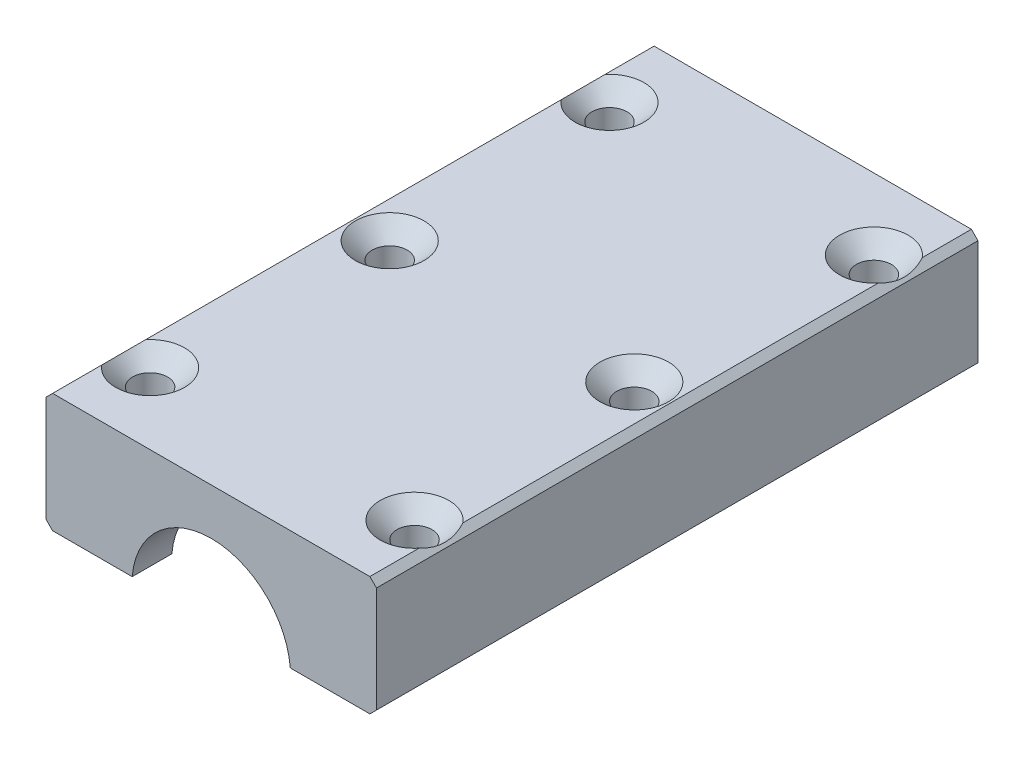
from build123d import *

# Parameters (mm, degrees)
BOSS_EXTRUDE1_DEPTH         = 91
CHAMFER1_SIZE               = 1
SKETCH2_W                   = 6.524852915
SKETCH2_H                   = 18.5
SKETCH2_W_2                 = 5.135295392
SKETCH2_H_2                 = 9.5
HOLE_WIZARD_M51_D           = 5.3
HOLE_WIZARD_M51_CSINK_D     = 10.4
HOLE_WIZARD_M51_CSINK_ANGLE = 90


with BuildPart() as part:
    # Sketch1 → Boss-Extrude1 (new body)
    with BuildSketch(Plane.XY):
        with BuildLine():
            Line((11.958260743, 1), (25, 1))
            Line((25, 1), (25, 19))
            Line((25, 19), (-25, 19))
            Line((-25, 19), (-25, 1))
            Line((-25, 1), (-11.958260743, 1))
            ThreePointArc((-11.958260743, 1), (0, 12), (11.958260743, 1))
        make_face()
    extrude(amount=-BOSS_EXTRUDE1_DEPTH)

    # Chamfer1
    chamfer1_edges = [part.edges().sort_by_distance(p)[0] for p in [
        (-25, 19, -45.5),
        (25, 19, -45.5),
        (25, 1, -45.5),
        (-25, 1, -45.5),
    ]]
    chamfer(chamfer1_edges, length=CHAMFER1_SIZE)

    # Sketch2 → Cut-Revolve2 (revolve, cut)
    with BuildSketch(Plane.XZ):
        with Locations((11.737573543, -15.25)):
            Rectangle(SKETCH2_W, SKETCH2_H)
        with Locations((12.432352304, -80.25)):
            Rectangle(SKETCH2_W_2, SKETCH2_H_2)
    revolve(axis=Axis((0, 0, 0), (0, 0, -1)), mode=Mode.SUBTRACT)

    # Зенковка для  винта с плоской головкой M51 (through all)
    with Locations(Plane(origin=(0, 19, 0), x_dir=(1, 0, 0), z_dir=(0, 1, 0))):
        with Locations((-20, 80.25), (20, 80.25), (18.5, 45.5), (-18.5, 45.5), (-20, 10.75), (20, 10.75)):
            CounterSinkHole(HOLE_WIZARD_M51_D / 2, HOLE_WIZARD_M51_CSINK_D / 2, counter_sink_angle=HOLE_WIZARD_M51_CSINK_ANGLE)


solid = part.part
